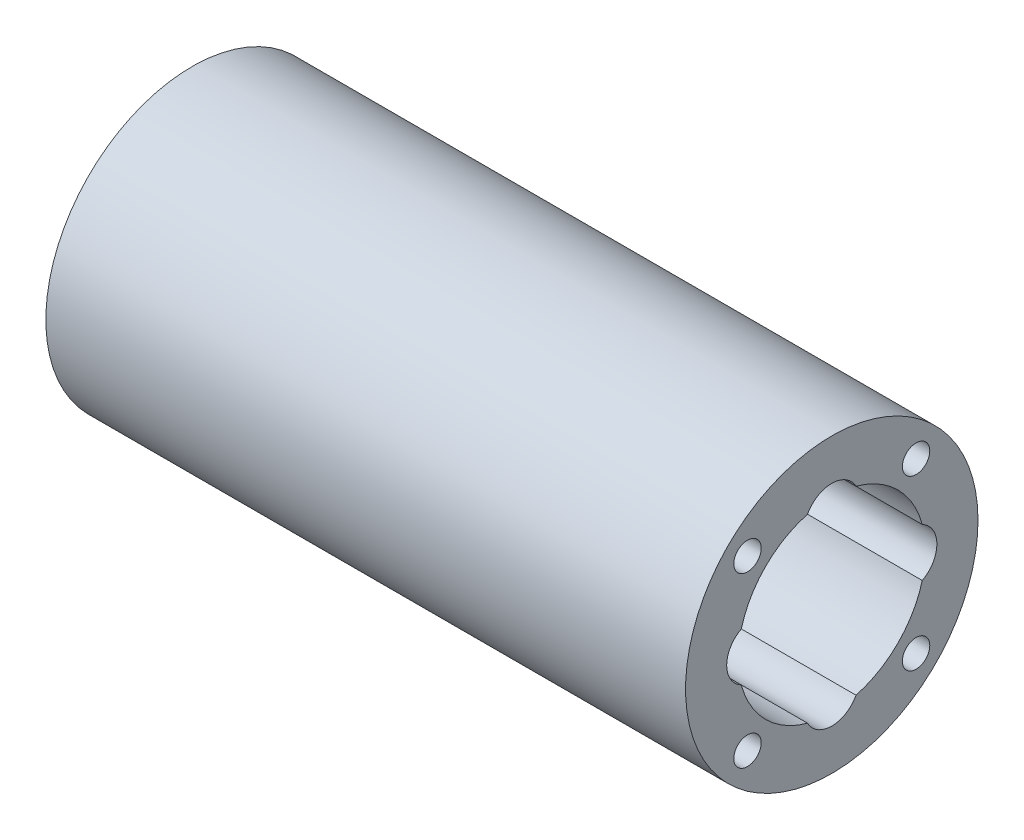
from build123d import *

# Parameters (mm, degrees)
SKETCH1_R           = 16
SKETCH1_R_2         = 1.5
SKETCH1_R_3         = 5.25
SKETCH1_R_4         = 3
BOSS_EXTRUDE2_DEPTH = 3
SKETCH1_8_R         = 16
BOSS_EXTRUDE4_DEPTH = 10
SKETCH1_10_R        = 3
SKETCH1_10_R_2      = 1.5
BOSS_EXTRUDE6_DEPTH = 3
BOSS_EXTRUDE7_START = 3
SKETCH1_11_R        = 16
BOSS_EXTRUDE7_DEPTH = 57
CUT_EXTRUDE2_START  = -70
SKETCH2_R           = 1.5
CUT_EXTRUDE2_DEPTH  = 5


with BuildPart() as part:
    # Sketch1 → Boss-Extrude2 (new body)
    with BuildSketch(Plane(origin=(0, 0, 0), x_dir=(0, 0, -1), z_dir=(1, 0, 0))):
        Circle(SKETCH1_R)
        with Locations((0, 8.5)):
            Circle(SKETCH1_R_2, mode=Mode.SUBTRACT)
        with Locations((0, -8.5)):
            Circle(SKETCH1_R_2, mode=Mode.SUBTRACT)
        Circle(SKETCH1_R_3, mode=Mode.SUBTRACT)
        with Locations((8.5, 0)):
            Circle(SKETCH1_R_4, mode=Mode.SUBTRACT)
        with Locations((-8.5, 0)):
            Circle(SKETCH1_R_4, mode=Mode.SUBTRACT)
    extrude(amount=BOSS_EXTRUDE2_DEPTH)

    # Sketch1_8 → Boss-Extrude4 (add)
    with BuildSketch(Plane(origin=(0, 0, 0), x_dir=(0, 0, -1), z_dir=(1, 0, 0))):
        Circle(SKETCH1_8_R)
        with BuildLine():
            ThreePointArc((2.652911728, 9.900735294), (7.247844507, 7.247844507), (9.900735294, 2.652911728))
            ThreePointArc((9.900735294, 2.652911728), (11.069261166, 1.548837325), (11.5, 0))
            ThreePointArc((11.5, 0), (11.069261166, -1.548837325), (9.900735294, -2.652911728))
            ThreePointArc((9.900735294, -2.652911728), (7.247844507, -7.247844507), (2.652911728, -9.900735294))
            ThreePointArc((2.652911728, -9.900735294), (0, -11.5), (-2.652911728, -9.900735294))
            ThreePointArc((-2.652911728, -9.900735294), (-7.247844507, -7.247844507), (-9.900735294, -2.652911728))
            ThreePointArc((-9.900735294, -2.652911728), (-11.5, 0), (-9.900735294, 2.652911728))
            ThreePointArc((-9.900735294, 2.652911728), (-7.247844507, 7.247844507), (-2.652911728, 9.900735294))
            ThreePointArc((-2.652911728, 9.900735294), (0, 11.5), (2.652911728, 9.900735294))
        make_face(mode=Mode.SUBTRACT)
    extrude(amount=-BOSS_EXTRUDE4_DEPTH)

    # Sketch1_10 → Boss-Extrude6 (add)
    with BuildSketch(Plane(origin=(0, 0, 0), x_dir=(0, 0, -1), z_dir=(1, 0, 0))):
        with Locations((8.5, 0)):
            Circle(SKETCH1_10_R)
        with Locations((8.5, 0)):
            Circle(SKETCH1_10_R_2, mode=Mode.SUBTRACT)
        with Locations((-8.5, 0)):
            Circle(SKETCH1_10_R)
        with Locations((-8.5, 0)):
            Circle(SKETCH1_10_R_2, mode=Mode.SUBTRACT)
    extrude(amount=BOSS_EXTRUDE6_DEPTH)

    # Sketch1_11 → Boss-Extrude7 (add)
    with BuildSketch(Plane(origin=(0, 0, 0), x_dir=(0, 0, -1), z_dir=(1, 0, 0)).offset(BOSS_EXTRUDE7_START)):
        Circle(SKETCH1_11_R)
        with BuildLine():
            ThreePointArc((2.652911728, 9.900735294), (7.247844507, 7.247844507), (9.900735294, 2.652911728))
            ThreePointArc((9.900735294, 2.652911728), (11.069261166, 1.548837325), (11.5, 0))
            ThreePointArc((11.5, 0), (11.069261166, -1.548837325), (9.900735294, -2.652911728))
            ThreePointArc((9.900735294, -2.652911728), (7.247844507, -7.247844507), (2.652911728, -9.900735294))
            ThreePointArc((2.652911728, -9.900735294), (0, -11.5), (-2.652911728, -9.900735294))
            ThreePointArc((-2.652911728, -9.900735294), (-7.247844507, -7.247844507), (-9.900735294, -2.652911728))
            ThreePointArc((-9.900735294, -2.652911728), (-11.5, 0), (-9.900735294, 2.652911728))
            ThreePointArc((-9.900735294, 2.652911728), (-7.247844507, 7.247844507), (-2.652911728, 9.900735294))
            ThreePointArc((-2.652911728, 9.900735294), (0, 11.5), (2.652911728, 9.900735294))
        make_face(mode=Mode.SUBTRACT)
    extrude(amount=BOSS_EXTRUDE7_DEPTH)

    # Sketch2 → Cut-Extrude2 (cut)
    with BuildSketch(Plane.ZY.offset(10).offset(CUT_EXTRUDE2_START)):
        with Locations(Location((9.222798741, 9.222798741, 0), (0, 0, 180))):
            Circle(SKETCH2_R)
        with Locations(Location((-9.222798741, 9.222798741, 0), (0, 0, 180))):
            Circle(SKETCH2_R)
        with Locations(Location((9.222798741, -9.222798741, 0), (0, 0, 180))):
            Circle(SKETCH2_R)
        with Locations(Location((-9.222798741, -9.222798741, 0), (0, 0, 180))):
            Circle(SKETCH2_R)
    extrude(amount=CUT_EXTRUDE2_DEPTH, mode=Mode.SUBTRACT)


solid = part.part
